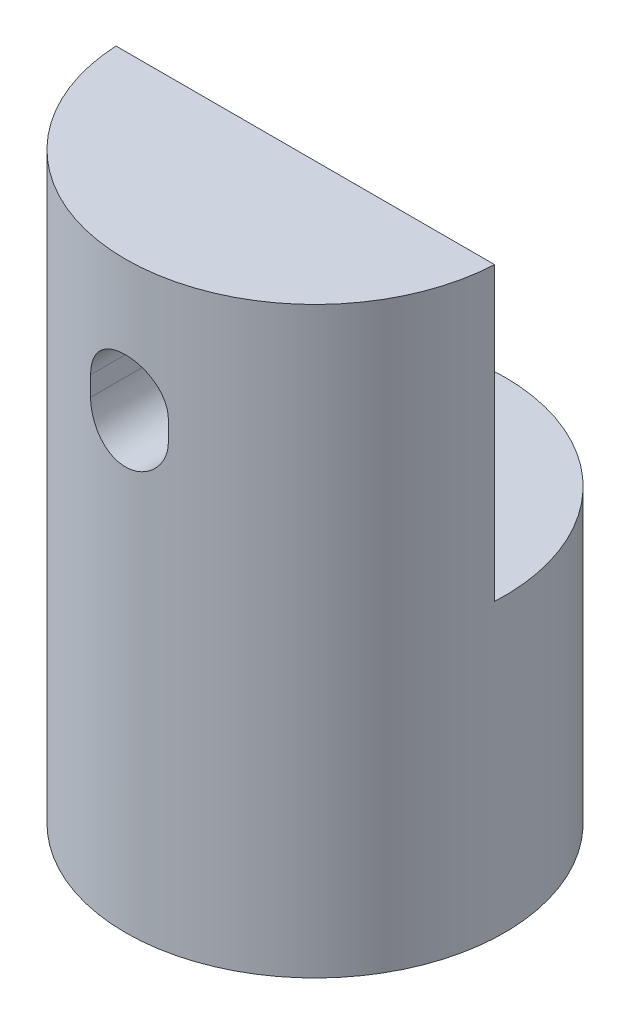
from build123d import *

# Parameters (mm, degrees)
SKETCH1_R               = 9.75
BOSS_EXTRUDE1_DEPTH     = 30
SKETCH3_W               = 19.5
SKETCH3_H               = 15
CUT_EXTRUDE1_DEPTH      = 0.5
CUT_EXTRUDE1_DEPTH_BACK = 30
CUT_EXTRUDE2_DEPTH      = 30


with BuildPart() as part:
    # Sketch1 → Boss-Extrude1 (new body)
    with BuildSketch(Plane(origin=(0, 0, 0), x_dir=(1, 0, 0), z_dir=(0, 1, 0))):
        Circle(SKETCH1_R)
    extrude(amount=BOSS_EXTRUDE1_DEPTH)

    # Sketch3 → Cut-Extrude1 (cut, two sides)
    with BuildSketch(Plane.XY) as cut_extrude1_sk:
        with Locations((0, 22.5)):
            Rectangle(SKETCH3_W, SKETCH3_H)
    extrude(amount=CUT_EXTRUDE1_DEPTH, mode=Mode.SUBTRACT)
    extrude(cut_extrude1_sk.sketch, amount=-CUT_EXTRUDE1_DEPTH_BACK, mode=Mode.SUBTRACT)

    # Sketch4 → Cut-Extrude2 (cut)
    with BuildSketch(Plane(origin=(0, 0, 0.5), x_dir=(-1, 0, 0), z_dir=(0, 0, -1))):
        with BuildLine():
            Line((2, 23.743843632), (2, 22.743843632))
            ThreePointArc((2, 22.743843632), (0, 20.743843632), (-2, 22.743843632))
            Line((-2, 22.743843632), (-2, 23.743843632))
            ThreePointArc((-2, 23.743843632), (0, 25.743843632), (2, 23.743843632))
        make_face()
    extrude(amount=-CUT_EXTRUDE2_DEPTH, mode=Mode.SUBTRACT)


solid = part.part
